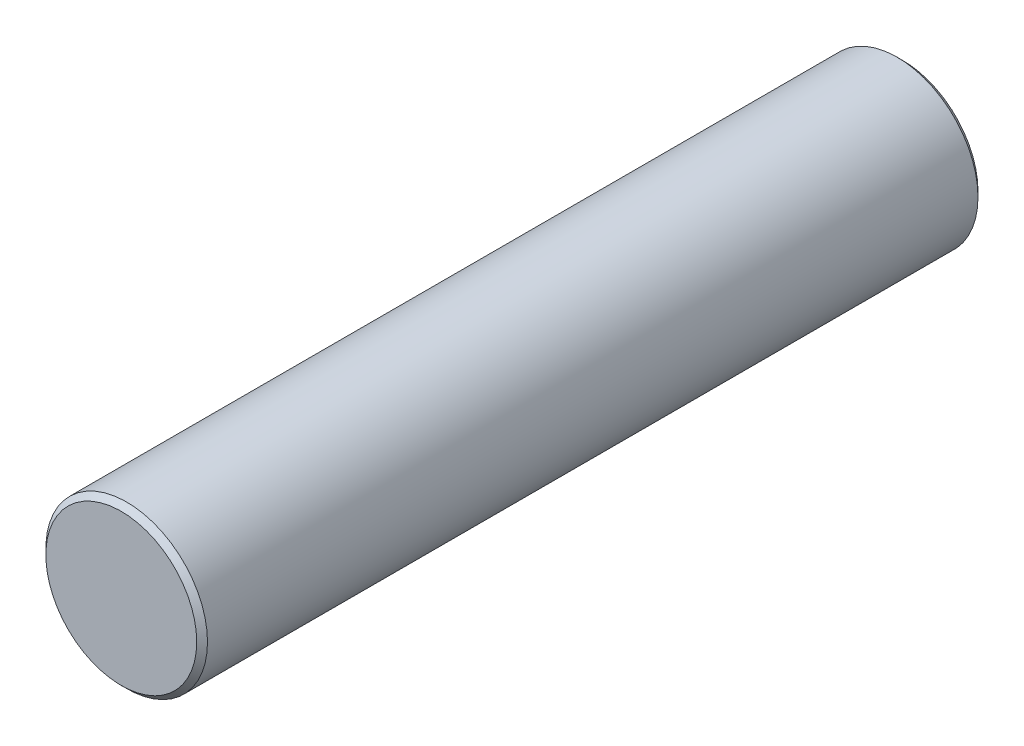
from build123d import *

# Parameters (mm, degrees)
SKETCH1_R           = 0.75
BOSS_EXTRUDE1_DEPTH = 7.25
CHAMFER1_SIZE       = 0.05


with BuildPart() as part:
    # Sketch1 → Boss-Extrude1 (new body)
    with BuildSketch(Plane.XY):
        Circle(SKETCH1_R)
    extrude(amount=BOSS_EXTRUDE1_DEPTH)

    # Chamfer1
    chamfer1_edges = [part.edges().sort_by_distance(p)[0] for p in [
        (-0.75, 0, 0),
        (-0.75, 0, 7.25),
    ]]
    chamfer(chamfer1_edges, length=CHAMFER1_SIZE)


solid = part.part
